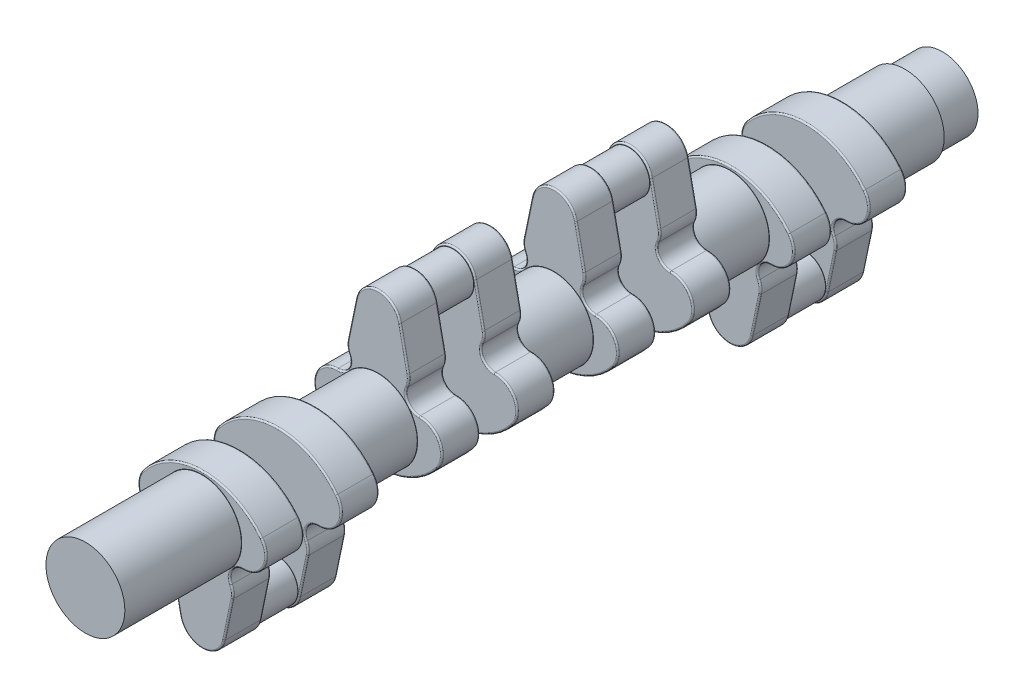
from build123d import *

# Parameters (mm, degrees)
BOSS_EXTRUDE1_DEPTH   = 20
SKETCH2_R             = 21
BOSS_EXTRUDE2_DEPTH   = 16.8
SKETCH3_R             = 11
BOSS_EXTRUDE3_DEPTH   = 10
FILLET1_R             = 10
FILLET2_R             = 0.8
FILLET3_R             = 0.1
LPATTERN1_COUNT       = 4
LPATTERN1_PITCH       = 93.6
BODY_MOVE_COPY1_ANGLE = 180
SKETCH5_R             = 21
BOSS_EXTRUDE4_DEPTH   = 16.3
SKETCH11_R            = 19
BOSS_EXTRUDE5_DEPTH   = 20
SKETCH12_R            = 21
BOSS_EXTRUDE6_DEPTH   = 25.3
SKETCH13_R            = 21
BOSS_EXTRUDE7_DEPTH   = 20


with BuildPart() as part:
    # Sketch1 → Boss-Extrude1 (new body)
    with BuildSketch(Plane.XY):
        with BuildLine():
            Line((-17.033997036, 1.066171201), (-11.749525199, -24.391133398))
            ThreePointArc((-11.749525199, -24.391133398), (-7.57403974, -31.259880922), (0, -33.952146396))
            ThreePointArc((0, -33.952146396), (7.57403974, -31.259880922), (11.749525199, -24.391133398))
            Line((11.749525199, -24.391133398), (17.033997036, 1.066171201))
            ThreePointArc((17.033997036, 1.066171201), (15.173636856, 8.847968986), (21.827496052, 13.291331967))
            ThreePointArc((21.827496052, 13.291331967), (32.796107007, 19.923991198), (31.517459592, 32.678114277))
            ThreePointArc((31.517459592, 32.678114277), (0, 48.047853604), (-31.517459592, 32.678114277))
            ThreePointArc((-31.517459592, 32.678114277), (-32.796107007, 19.923991198), (-21.827496052, 13.291331967))
            ThreePointArc((-21.827496052, 13.291331967), (-15.173636856, 8.847968986), (-17.033997036, 1.066171201))
        make_face()
    extrude(amount=BOSS_EXTRUDE1_DEPTH)

    # Sketch2 → Boss-Extrude2 (add)
    with BuildSketch(Plane(origin=(0, 0, 0), x_dir=(-1, 0, 0), z_dir=(0, 0, -1))):
        with Locations((0, 25.289036075)):
            Circle(SKETCH2_R)
    extrude(amount=BOSS_EXTRUDE2_DEPTH)

    # Sketch3 → Boss-Extrude3 (add)
    with BuildSketch(Plane.XY.offset(20)):
        with Locations((0, -21.952146396)):
            Circle(SKETCH3_R)
    extrude(amount=BOSS_EXTRUDE3_DEPTH)

    # Fillet1
    fillet1_edges = [part.edges().sort_by_distance(p)[0] for p in [
        (-17.033997036, 1.066171201, 10),
        (17.033997036, 1.066171201, 10),
    ]]
    fillet(fillet1_edges, radius=FILLET1_R)

    # Fillet2
    fillet2_edges = [part.edges().sort_by_distance(p)[0] for p in [
        (0, 48.047853604, 0),
        (32.796107007, 19.923991198, 0),
        (15.800120222, 10.074544985, 0),
        (16.300028665, 0.133734175, 0),
        (13.957628873, -13.753860734, 0),
        (0, -33.952146396, 0),
        (-13.957628873, -13.753860734, 0),
        (-16.300028665, 0.133734175, 0),
        (-15.800120222, 10.074544985, 0),
        (0, 48.047853604, 20),
        (32.796107007, 19.923991198, 20),
        (15.800120222, 10.074544985, 20),
        (16.300028665, 0.133734175, 20),
        (13.957628873, -13.753860734, 20),
        (0, -33.952146396, 20),
        (-13.957628873, -13.753860734, 20),
        (-16.300028665, 0.133734175, 20),
        (-15.800120222, 10.074544985, 20),
        (-32.796107007, 19.923991198, 0),
        (-32.796107007, 19.923991198, 20),
    ]]
    fillet(fillet2_edges, radius=FILLET2_R)

    # Fillet3
    fillet3_edges = [part.edges().sort_by_distance(p)[0] for p in [
        (-11, -21.952146396, 20),
        (21, 25.289036075, 0),
    ]]
    fillet(fillet3_edges, radius=FILLET3_R)

    # Mirror1: part across plane


with BuildPart() as part_1:
    add(part.part)
    add(part.part.mirror(Plane(origin=(0, -21.952146396, 30), x_dir=(1, 0, 0), z_dir=(0, 0, 1))))


with BuildPart() as lpattern1_1:
    # LPattern1: pattern copy
    add(part_1.part.moved(Location(Vector(0, 0, 1) * (1 * LPATTERN1_PITCH))))


with BuildPart() as lpattern1_2:
    # LPattern1: pattern copy
    add(part_1.part.moved(Location(Vector(0, 0, 1) * (2 * LPATTERN1_PITCH))))


with BuildPart() as lpattern1_3:
    # LPattern1: pattern copy
    add(part_1.part.moved(Location(Vector(0, 0, 1) * (3 * LPATTERN1_PITCH))))


with BuildPart() as lpattern1_2_1:
    # Body-Move_Copy1: moved
    add(lpattern1_2.part.rotate(Axis((0, 25.289036075, 0), (0, 0, 1)), BODY_MOVE_COPY1_ANGLE))


with BuildPart() as lpattern1_1_1:
    # Body-Move_Copy1: moved
    add(lpattern1_1.part.rotate(Axis((0, 25.289036075, 0), (0, 0, 1)), BODY_MOVE_COPY1_ANGLE))


with BuildPart() as lpattern1_3_1:
    add(lpattern1_3.part)

    # Combine1: union LPattern1_2, LPattern1_1, part
    add(lpattern1_2_1.part)
    add(lpattern1_1_1.part)
    add(part_1.part)

    # Sketch5 → Boss-Extrude4 (add)
    with BuildSketch(Plane(origin=(0, 0, -16.8), x_dir=(-1, 0, 0), z_dir=(0, 0, -1))):
        with Locations((0, 25.289036075)):
            Circle(SKETCH5_R)
    extrude(amount=BOSS_EXTRUDE4_DEPTH)

    # Sketch11 → Boss-Extrude5 (add)
    with BuildSketch(Plane(origin=(0, 0, -33.1), x_dir=(-1, 0, 0), z_dir=(0, 0, -1))):
        with Locations((0, 25.289036075)):
            Circle(SKETCH11_R)
    extrude(amount=BOSS_EXTRUDE5_DEPTH)

    # Sketch12 → Boss-Extrude6 (add)
    with BuildSketch(Plane.XY.offset(357.6)):
        with Locations((0, 25.289036075)):
            Circle(SKETCH12_R)
    extrude(amount=BOSS_EXTRUDE6_DEPTH)

    # Sketch13 → Boss-Extrude7 (add)
    with BuildSketch(Plane.XY.offset(382.9)):
        with Locations((0, 25.289036075)):
            Circle(SKETCH13_R)
    extrude(amount=BOSS_EXTRUDE7_DEPTH)


solid = lpattern1_3_1.part
